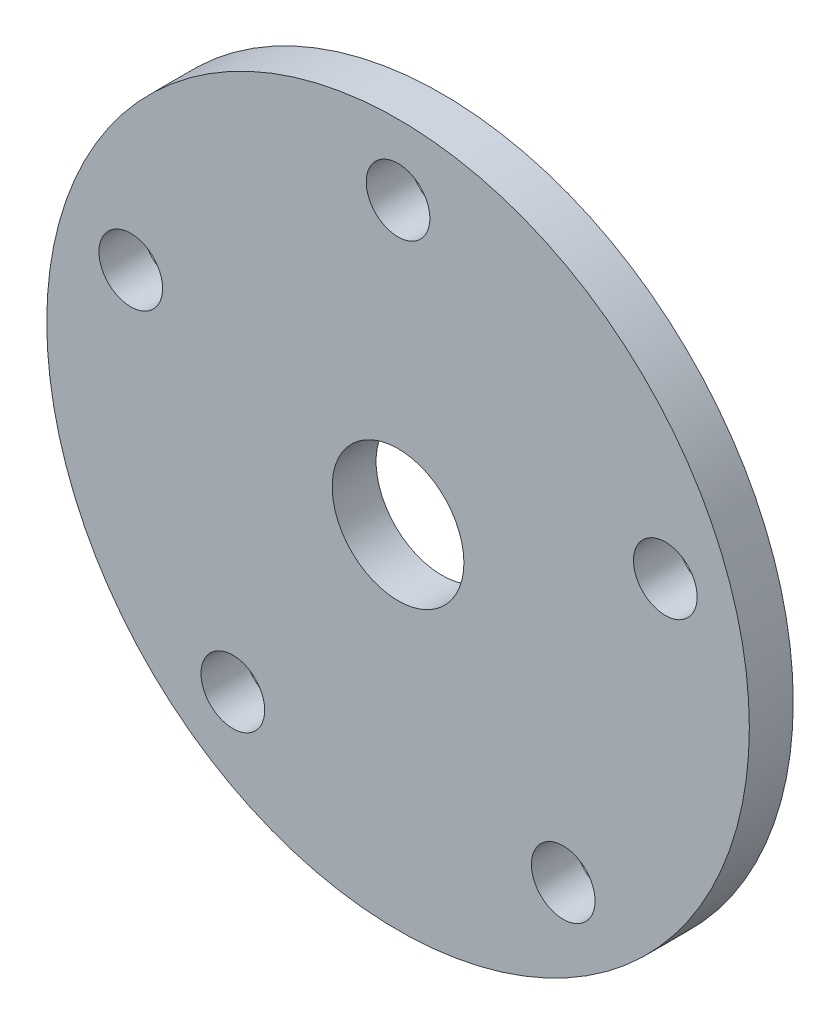
from build123d import *

# Parameters (mm, degrees)
ESQUISSE1_R                  = 80
ESQUISSE1_R_2                = 15
BOSS_EXTRU_1_DEPTH           = 5
ESQUISSE3_R                  = 7.25
ENL_V_MAT_EXTRU_1_DEPTH      = 10
R_P_TITION_CIRCULAIRE4_COUNT = 5


with BuildPart() as part:
    # Esquisse1 → Boss.-Extru.1 (new body, symmetric)
    with BuildSketch(Plane.XY):
        Circle(ESQUISSE1_R)
        Circle(ESQUISSE1_R_2, mode=Mode.SUBTRACT)
    extrude(amount=BOSS_EXTRU_1_DEPTH, both=True)

    # Esquisse3 → Enlèv. mat.-Extru.1 (cut)
    with BuildSketch(Plane.XY.offset(5)):
        with Locations((0, 64)):
            Circle(ESQUISSE3_R)
    enl_v_mat_extru_1 = extrude(amount=-ENL_V_MAT_EXTRU_1_DEPTH, mode=Mode.SUBTRACT)

    # Répétition circulaire4: Enlèv. mat.-Extru.1 ×5 about axis
    r_p_tition_circulaire4_axis = Axis((0, 0, 0), (0, 0, 1))
    for i in range(1, R_P_TITION_CIRCULAIRE4_COUNT):
        add(enl_v_mat_extru_1.rotate(r_p_tition_circulaire4_axis, i * 360 / R_P_TITION_CIRCULAIRE4_COUNT), mode=Mode.SUBTRACT)


solid = part.part
